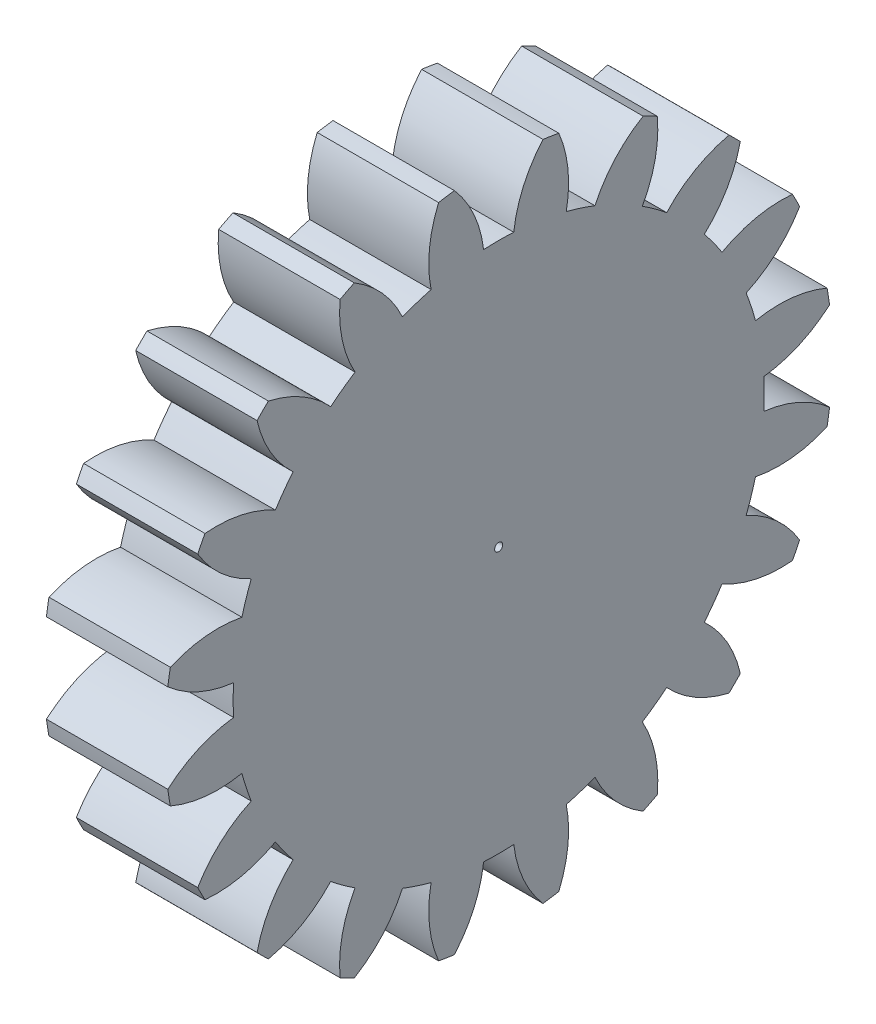
from build123d import *

# Parameters (mm, degrees)
BASPROSKE_W     = 12
BASPROSKE_H     = 33
TOOTHCUT_DEPTH  = 49.187135213
TEETHCUTS_COUNT = 20
TEETHCUTS_ANGLE = 342
BORSKE_R        = 0.4
BORE_DEPTH      = 50.0000508


with BuildPart() as part:
    # BasProSke → Base-Revolve (revolve)
    with BuildSketch(Plane(origin=(0, 0, 0), x_dir=(1, 0, 0), z_dir=(0, 1, 0)), mode=Mode.PRIVATE) as base_revolve_sk:
        with Locations((6, 16.5)):
            Rectangle(BASPROSKE_W, BASPROSKE_H)
    revolve(base_revolve_sk.sketch.rotate(Axis((-10, 0, 0), (1, 0, 0)), 180), axis=Axis((-10, 0, 0), (1, 0, 0)))

    # TooCutSke → ToothCut (cut, through all)
    with BuildSketch(Plane(origin=(0, 0, 0), x_dir=(0, 0, -1), z_dir=(1, 0, 0))):
        with BuildLine():
            ThreePointArc((1.489278925, 26.206717637), (0, 26.249), (-1.489278925, 26.206717637))
            ThreePointArc((-1.489278925, 26.206717637), (-2.448651415, 29.690511169), (-4.401620335, 32.730762038))
            ThreePointArc((-4.401620335, 32.730762038), (0, 33.0254), (4.401620335, 32.730762038))
            ThreePointArc((4.401620335, 32.730762038), (2.448651415, 29.690511169), (1.489278925, 26.206717637))
        make_face()
    toothcut = extrude(amount=TOOTHCUT_DEPTH, mode=Mode.SUBTRACT)

    # TeethCuts: ToothCut ×20 about axis
    teethcuts_axis = Axis((-10, 0, 0), (1, 0, 0))
    for i in range(1, TEETHCUTS_COUNT):
        add(toothcut.rotate(teethcuts_axis, i * TEETHCUTS_ANGLE / (TEETHCUTS_COUNT - 1)), mode=Mode.SUBTRACT)

    # BorSke → Bore (cut, symmetric)
    with BuildSketch(Plane(origin=(0, 0, 0), x_dir=(0, 0, -1), z_dir=(1, 0, 0))):
        with Locations(Location((0, 0, 0), (0, 0, 180))):
            Circle(BORSKE_R)
    extrude(amount=BORE_DEPTH, both=True, mode=Mode.SUBTRACT)


solid = part.part
